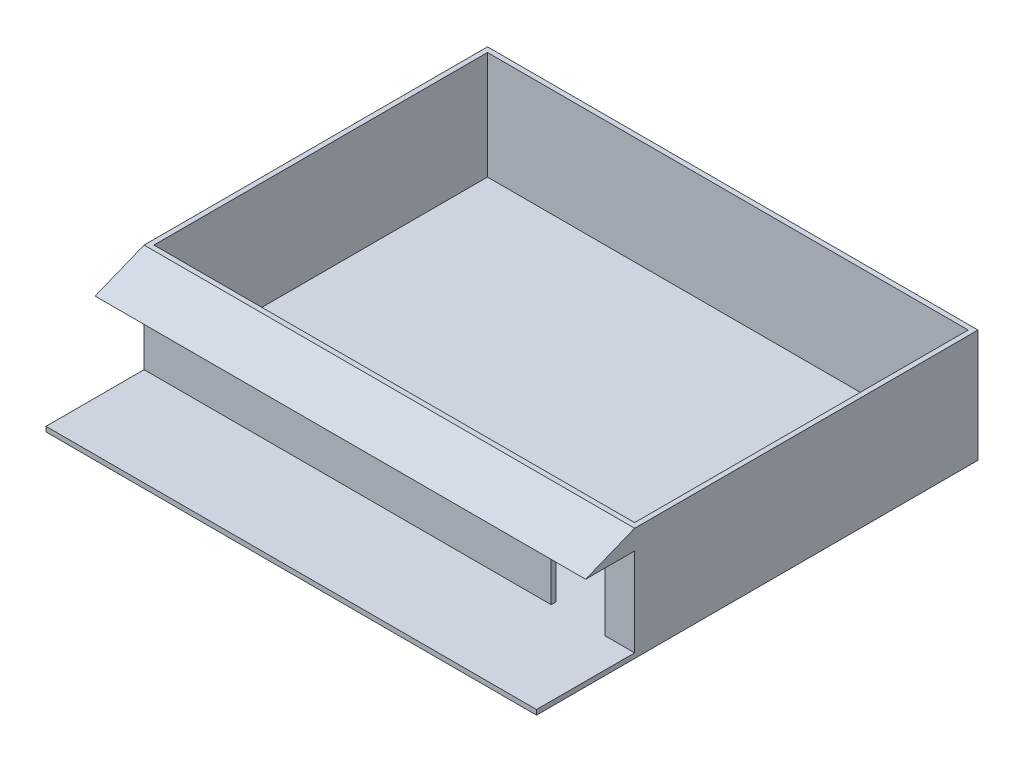
from build123d import *

# Parameters (mm, degrees)
SKETCH1_W           = 1000
SKETCH1_H           = 900
BOSS_EXTRUDE1_DEPTH = 10
SKETCH2_W           = 1000
SKETCH2_H           = 700
SKETCH2_W_2         = 980
SKETCH2_H_2         = 680
BOSS_EXTRUDE2_DEPTH = 220
SKETCH3_W           = 110
SKETCH3_H           = 170
CUT_EXTRUDE1_DEPTH  = 280
BOSS_EXTRUDE3_DEPTH = 1000


with BuildPart() as part:
    # Sketch1 → Boss-Extrude1 (new body)
    with BuildSketch(Plane(origin=(0, 0, 0), x_dir=(1, 0, 0), z_dir=(0, 1, 0))):
        Rectangle(SKETCH1_W, SKETCH1_H)
    extrude(amount=BOSS_EXTRUDE1_DEPTH)

    # Sketch2 → Boss-Extrude2 (add)
    with BuildSketch(Plane(origin=(0, 10, 0), x_dir=(1, 0, 0), z_dir=(0, 1, 0))):
        with Locations((0, 100)):
            Rectangle(SKETCH2_W, SKETCH2_H)
        with Locations((0, 100)):
            Rectangle(SKETCH2_W_2, SKETCH2_H_2, mode=Mode.SUBTRACT)
    extrude(amount=BOSS_EXTRUDE2_DEPTH)

    # Sketch3 → Cut-Extrude1 (cut)
    with BuildSketch(Plane.XY.offset(450)):
        with Locations((385, 95)):
            Rectangle(SKETCH3_W, SKETCH3_H)
    extrude(amount=-CUT_EXTRUDE1_DEPTH, mode=Mode.SUBTRACT)

    # Sketch5 → Boss-Extrude3 (add)
    with BuildSketch(Plane.ZY.offset(500)):
        Polygon((250, 230), (350, 190), (250, 190), align=None)
    extrude(amount=-BOSS_EXTRUDE3_DEPTH)


solid = part.part
